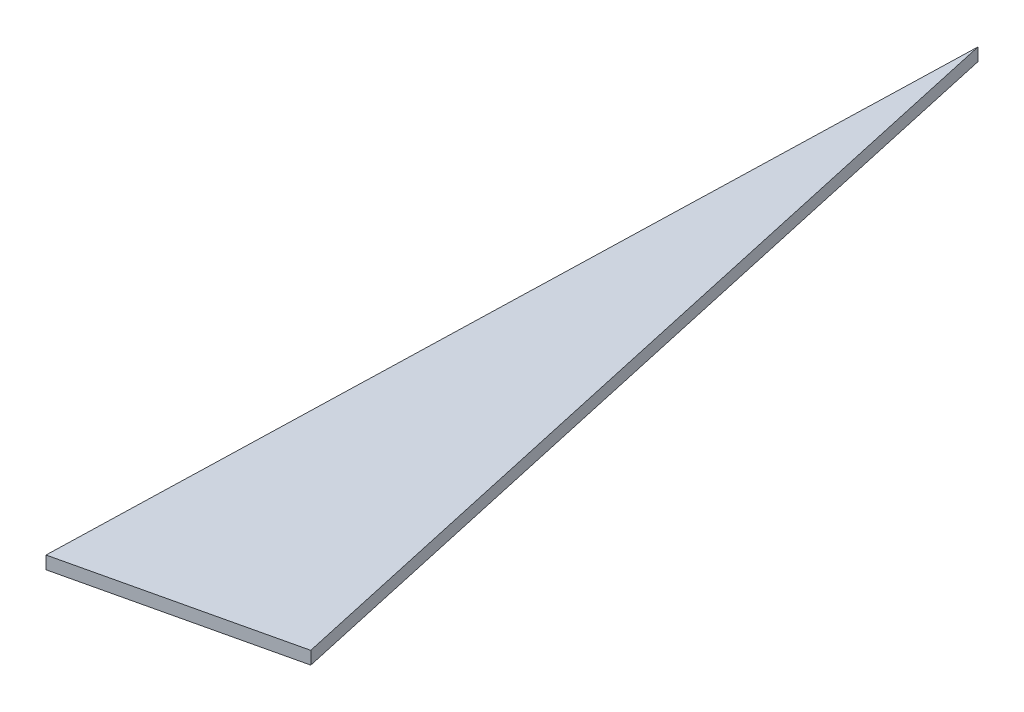
from build123d import *

# Parameters (mm, degrees)
BOSS_EXTRU_1_DEPTH = 2


with BuildPart() as part:
    # Esquisse1 → Boss.-Extru.1 (new body)
    with BuildSketch(Plane(origin=(0, 0, 0), x_dir=(1, 0, 0), z_dir=(0, 1, 0))):
        Polygon((33.551530257, 7.774211742), (4.052148419, 141.414149334), (0, 0), align=None)
    extrude(amount=BOSS_EXTRU_1_DEPTH)


solid = part.part
